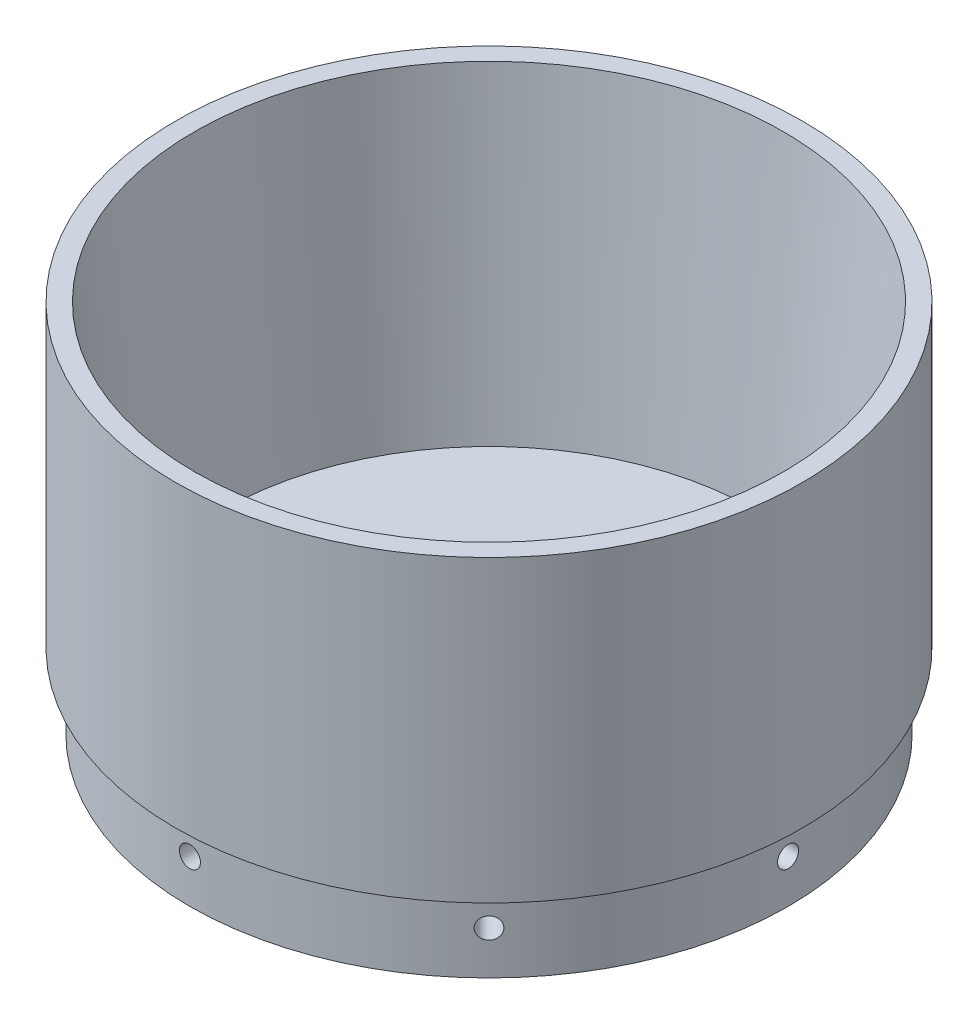
from build123d import *

# Parameters (mm, degrees)
SKETCH1_R           = 53.18125
BOSS_EXTRUDE1_DEPTH = 50.8
SKETCH2_R           = 50.8
SKETCH2_R_2         = 47.625
BOSS_EXTRUDE2_DEPTH = 12.7
SKETCH3_R           = 50.00625
CUT_EXTRUDE1_DEPTH  = 53.34
CUT_EXTRUDE1_DRAFT  = -5
SKETCH4_R           = 3.302
CUT_EXTRUDE2_DEPTH  = 93.204372473
SKETCH5_R           = 1.7859375
CUT_EXTRUDE3_DEPTH  = 10.16
CIRPATTERN1_COUNT   = 8


with BuildPart() as part:
    # Sketch1 → Boss-Extrude1 (new body)
    with BuildSketch(Plane(origin=(0, 0, 0), x_dir=(1, 0, 0), z_dir=(0, 1, 0))):
        with Locations(Location((0, 0, 0), (0, 0, 270))):
            Circle(SKETCH1_R)
    extrude(amount=BOSS_EXTRUDE1_DEPTH)

    # Sketch2 → Boss-Extrude2 (add)
    with BuildSketch(Plane.XZ):
        with Locations(Location((0, 0, 0), (0, 0, 270))):
            Circle(SKETCH2_R)
        Circle(SKETCH2_R_2, mode=Mode.SUBTRACT)
        Circle(SKETCH2_R_2)
    extrude(amount=BOSS_EXTRUDE2_DEPTH)


with BuildPart() as cut_extrude1_tool:
    # Sketch3 → Cut-Extrude1 (with draft: the straight prism first)
    with BuildSketch(Plane(origin=(0, 50.8, 0), x_dir=(1, 0, 0), z_dir=(0, 1, 0))):
        Circle(SKETCH3_R)
    extrude(amount=-CUT_EXTRUDE1_DEPTH)
    # Cut-Extrude1: the draft: its side faces are tilted about the plane it starts from
    cut_extrude1_sides = [cut_extrude1_tool.faces().sort_by_distance(p)[0] for p in [
        (-50.00625, 24.13, 0),
    ]]
    draft(cut_extrude1_sides, Plane(origin=(0, 50.8, 0), x_dir=(1, 0, 0), z_dir=(0, 1, 0)), CUT_EXTRUDE1_DRAFT)


with BuildPart() as part_1:
    add(part.part)

    # Cut-Extrude1: cut by cut_extrude1_tool
    add(cut_extrude1_tool.part, mode=Mode.SUBTRACT)

    # Sketch4 → Cut-Extrude2 (cut, through all)
    with BuildSketch(Plane(origin=(0, -2.54, 0), x_dir=(1, 0, 0), z_dir=(0, 1, 0))):
        with Locations(Location((0, 0, 0), (0, 0, 270))):
            Circle(SKETCH4_R)
    extrude(amount=-CUT_EXTRUDE2_DEPTH, mode=Mode.SUBTRACT)

    # Sketch5 → Cut-Extrude3 (cut)
    with BuildSketch(Plane(origin=(50.8, 0, 0), x_dir=(0, 0, -1), z_dir=(1, 0, 0))):
        with Locations((0, -5.35305)):
            Circle(SKETCH5_R)
    cut_extrude3 = extrude(amount=-CUT_EXTRUDE3_DEPTH, mode=Mode.SUBTRACT)

    # CirPattern1: Cut-Extrude3 ×8 about axis
    cirpattern1_axis = Axis((0, 0, 0), (0, 1, 0))
    for i in range(1, CIRPATTERN1_COUNT):
        add(cut_extrude3.rotate(cirpattern1_axis, i * 360 / CIRPATTERN1_COUNT), mode=Mode.SUBTRACT)


solid = part_1.part
